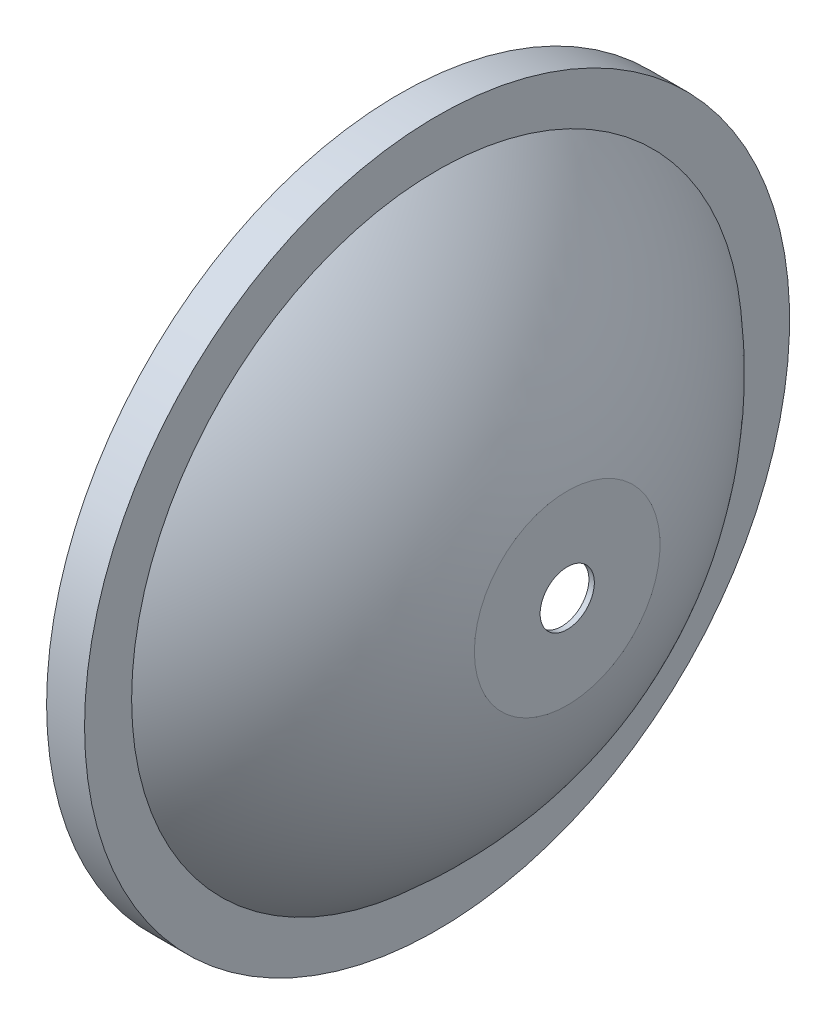
from build123d import *


with BuildPart() as part:
    # Sketch1 → Revolve1 (revolve)
    with BuildSketch(Plane.XY):
        with BuildLine():
            Line((-29.992957397, 64), (-23.992957397, 64))
            Line((-23.992957397, 64), (-23.992957397, 55.856960175))
            ThreePointArc((-23.992957397, 55.856960175), (-8.879751576, 38.352961589), (0, 17))
            Line((0, 17), (0, 5))
            Line((0, 5), (1, 5))
            Line((1, 5), (1, 17.117654197))
            ThreePointArc((1, 17.117654197), (-7.875658194, 38.629089315), (-22.992957397, 56.320511361))
            Line((-22.992957397, 56.320511361), (-22.992957397, 65))
            Line((-22.992957397, 65), (-29.992957397, 65))
            Line((-29.992957397, 65), (-29.992957397, 64))
        make_face()
    revolve(axis=Axis((-110.416386088, 0, 0), (1, 0, 0)))


solid = part.part
